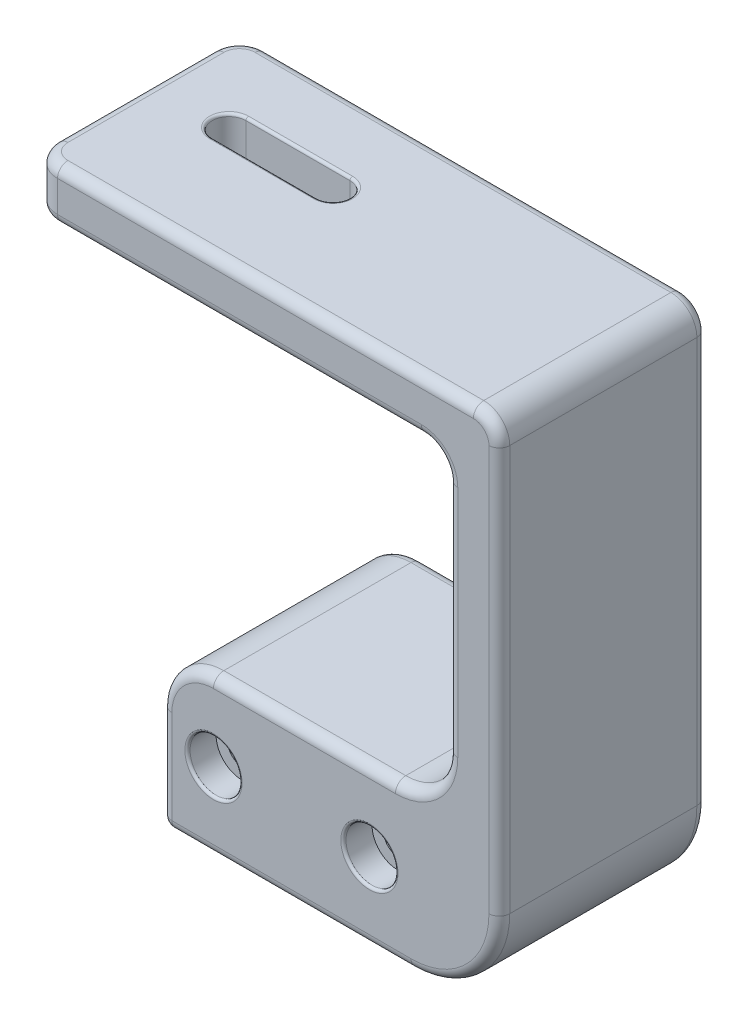
from build123d import *

# Parameters (mm, degrees)
AUFSATZ_LINEAR_AUSTRAGEN1_DEPTH                     = 20
SCHNITT_LINEAR_AUSTRAGEN1_DEPTH                     = 20
SKIZZE7_R                                           = 4
SCHNITT_LINEAR_AUSTRAGEN3_DEPTH                     = 12
STIRNSENKUNG_FUR_M3_SENKSCHRAUBE_KOPF_B_D           = 5.5
STIRNSENKUNG_FUR_M3_SENKSCHRAUBE_KOPF_B_CBORE_D     = 10
STIRNSENKUNG_FUR_M3_SENKSCHRAUBE_KOPF_B_CBORE_DEPTH = 5.5
VERRUNDUNG5_R                                       = 17
VERRUNDUNG6_R                                       = 10
VERRUNDUNG7_R                                       = 10
VERRUNDUNG9_R                                       = 5
VERRUNDUNG10_R                                      = 2
VERRUNDUNG11_R                                      = 0.5


with BuildPart() as part:
    # Skizze1 → Aufsatz-Linear austragen1 (new body, symmetric)
    with BuildSketch(Plane.XY):
        Polygon((-50, 100), (-50, 90), (30, 90), (30, 30), (-25, 30), (-25, 0), (40, 0), (40, 100), align=None)
    extrude(amount=AUFSATZ_LINEAR_AUSTRAGEN1_DEPTH, both=True)

    # Skizze3 → Schnitt-Linear austragen1 (cut)
    with BuildSketch(Plane(origin=(0, 100, 0), x_dir=(1, 0, 0), z_dir=(0, 1, 0))):
        with BuildLine():
            Line((-35, 6.25), (-15, 6.25))
            ThreePointArc((-15, 6.25), (-11.75, 3), (-15, -0.25))
            Line((-15, -0.25), (-35, -0.25))
            ThreePointArc((-35, -0.25), (-38.25, 3), (-35, 6.25))
        make_face()
    extrude(amount=-SCHNITT_LINEAR_AUSTRAGEN1_DEPTH, mode=Mode.SUBTRACT)

    # Skizze7 → Schnitt-Linear austragen3 (cut)
    with BuildSketch(Plane.XZ):
        with Locations((0, 10)):
            Circle(SKIZZE7_R)
        with Locations((0, -10)):
            Circle(SKIZZE7_R)
    extrude(amount=-SCHNITT_LINEAR_AUSTRAGEN3_DEPTH, mode=Mode.SUBTRACT)

    # Stirnsenkung fur M3 Senkschraube (Kopf Button)1 (through all)
    with Locations(Plane(origin=(-15, 15, 20), x_dir=(1, 0, 0), z_dir=(0, 0, 1))):
        with Locations((0, 0), (30, 0)):
            CounterBoreHole(STIRNSENKUNG_FUR_M3_SENKSCHRAUBE_KOPF_B_D / 2, STIRNSENKUNG_FUR_M3_SENKSCHRAUBE_KOPF_B_CBORE_D / 2, STIRNSENKUNG_FUR_M3_SENKSCHRAUBE_KOPF_B_CBORE_DEPTH)

    # Verrundung5
    verrundung5_edges = [part.edges().sort_by_distance(p)[0] for p in [
        (40, 0, 0),
    ]]
    fillet(verrundung5_edges, radius=VERRUNDUNG5_R)

    # Verrundung6
    verrundung6_edges = [part.edges().sort_by_distance(p)[0] for p in [
        (30, 30, 0),
    ]]
    fillet(verrundung6_edges, radius=VERRUNDUNG6_R)

    # Verrundung7
    verrundung7_edges = [part.edges().sort_by_distance(p)[0] for p in [
        (-25, 30, 0),
    ]]
    fillet(verrundung7_edges, radius=VERRUNDUNG7_R)

    # Verrundung9
    verrundung9_edges = [part.edges().sort_by_distance(p)[0] for p in [
        (30, 90, 0),
        (40, 100, 0),
        (-50, 95, 20),
        (-50, 95, -20),
    ]]
    fillet(verrundung9_edges, radius=VERRUNDUNG9_R)

    # Verrundung10
    verrundung10_edges = [part.edges().sort_by_distance(p)[0] for p in [
        (-1, 0, 20),
        (-25, 0, 0),
        (40, 56, -20),
        (40, 56, 20),
        (35.02081528, 4.97918472, -20),
        (35.02081528, 4.97918472, 20),
        (2.5, 30, -20),
        (2.5, 30, 20),
        (27.071067812, 32.928932188, -20),
        (27.071067812, 32.928932188, 20),
        (-25, 10, -20),
        (-25, 10, 20),
        (-22.071067812, 27.071067812, -20),
        (-22.071067812, 27.071067812, 20),
        (-5, 100, 20),
        (-10, 90, 20),
        (30, 62.5, 20),
        (38.535533906, 98.535533906, 20),
        (-10, 90, -20),
        (-50, 90, 0),
        (-48.535533906, 90, -18.535533906),
        (-48.535533906, 90, 18.535533906),
        (-50, 100, 0),
        (-5, 100, -20),
        (-48.535533906, 100, -18.535533906),
        (-48.535533906, 100, 18.535533906),
        (30, 62.5, -20),
        (-1, 0, -20),
        (38.535533906, 98.535533906, -20),
        (28.535533906, 88.535533906, -20),
        (28.535533906, 88.535533906, 20),
    ]]
    fillet(verrundung10_edges, radius=VERRUNDUNG10_R)

    # Verrundung11
    verrundung11_edges = [part.edges().sort_by_distance(p)[0] for p in [
        (-25, 90, 0.25),
        (-11.75, 90, -3),
        (-25, 90, -6.25),
        (-38.25, 90, -3),
        (-38.25, 100, -3),
        (-25, 100, 0.25),
        (-11.75, 100, -3),
        (-25, 100, -6.25),
        (10, 15, 20),
        (-20, 15, 20),
    ]]
    fillet(verrundung11_edges, radius=VERRUNDUNG11_R)


solid = part.part
